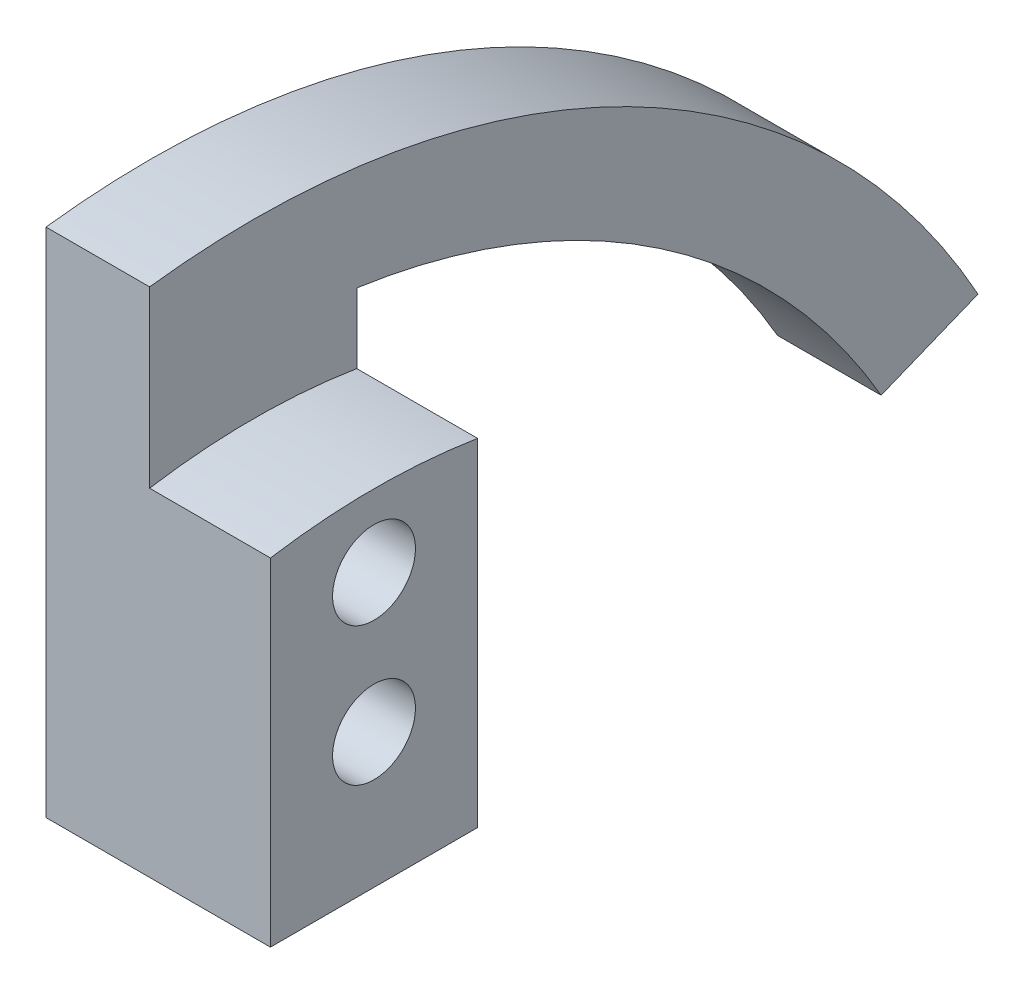
from build123d import *

# Parameters (mm, degrees)
CROQUIS1_R              = 0.6
SALIENTE_EXTRUIR1_DEPTH = 1.5
CROQUIS2_R              = 0.6
SALIENTE_EXTRUIR2_DEPTH = 1.75


with BuildPart() as part:
    # Croquis1 → Saliente-Extruir1 (new body)
    with BuildSketch(Plane(origin=(0, 0, 0), x_dir=(0, 0, -1), z_dir=(1, 0, 0))):
        with BuildLine():
            Line((-1.5, 4.5), (1.5, 4.5))
            Line((1.5, 4.5), (1.5, 10.392304845))
            ThreePointArc((1.5, 10.392304845), (5.887711766, 8.693954806), (9.09326674, 5.25))
            Line((9.09326674, 5.25), (10.495980844, 5.816733286))
            ThreePointArc((10.495980844, 5.816733286), (5.431514292, 10.700404315), (-1.5, 11.9058809))
            Line((-1.5, 11.9058809), (-1.5, 4.5))
        make_face()
        with Locations((0, 8.45)):
            Circle(CROQUIS1_R, mode=Mode.SUBTRACT)
        with Locations((0, 6.45)):
            Circle(CROQUIS1_R, mode=Mode.SUBTRACT)
    extrude(amount=SALIENTE_EXTRUIR1_DEPTH)

    # Croquis2 → Saliente-Extruir2 (add)
    with BuildSketch(Plane(origin=(1.5, 0, 0), x_dir=(0, 0, -1), z_dir=(1, 0, 0))):
        with BuildLine():
            Line((-1.5, 4.5), (1.5, 4.5))
            Line((1.5, 4.5), (1.5, 9.38083152))
            ThreePointArc((1.5, 9.38083152), (0, 9.5), (-1.5, 9.38083152))
            Line((-1.5, 9.38083152), (-1.5, 4.5))
        make_face()
        with Locations((0, 6.45)):
            Circle(CROQUIS2_R, mode=Mode.SUBTRACT)
        with Locations((0, 8.45)):
            Circle(CROQUIS2_R, mode=Mode.SUBTRACT)
    extrude(amount=SALIENTE_EXTRUIR2_DEPTH)


solid = part.part
